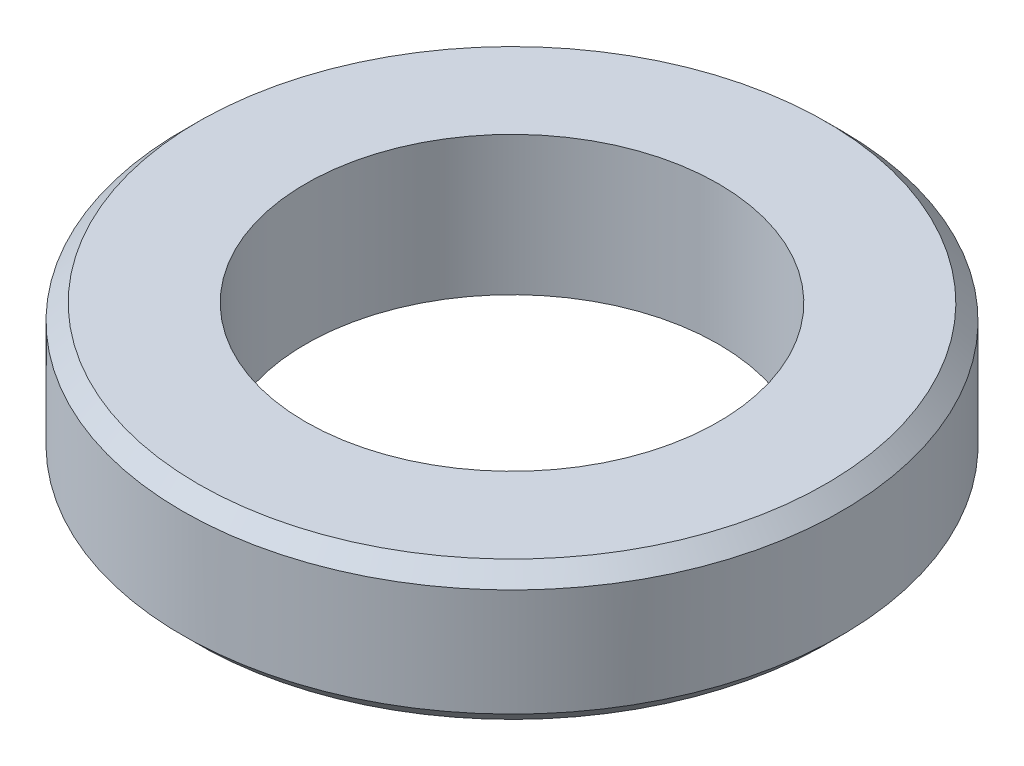
from build123d import *

# Parameters (mm, degrees)
SKETCH1_W     = 3.9878
SKETCH1_H     = 4.4958
CHAMFER1_SIZE = 0.508


with BuildPart() as part:
    # Sketch1 → Revolve1 (revolve)
    with BuildSketch(Plane.XY):
        with Locations((8.6741, -2.2479)):
            Rectangle(SKETCH1_W, SKETCH1_H)
    revolve(axis=Axis((0, 0, 0), (0, -1, 0)))

    # Chamfer1
    chamfer1_edges = [part.edges().sort_by_distance(p)[0] for p in [
        (-10.668, -4.4958, 0),
        (-10.668, 0, 0),
    ]]
    chamfer(chamfer1_edges, length=CHAMFER1_SIZE)


solid = part.part
